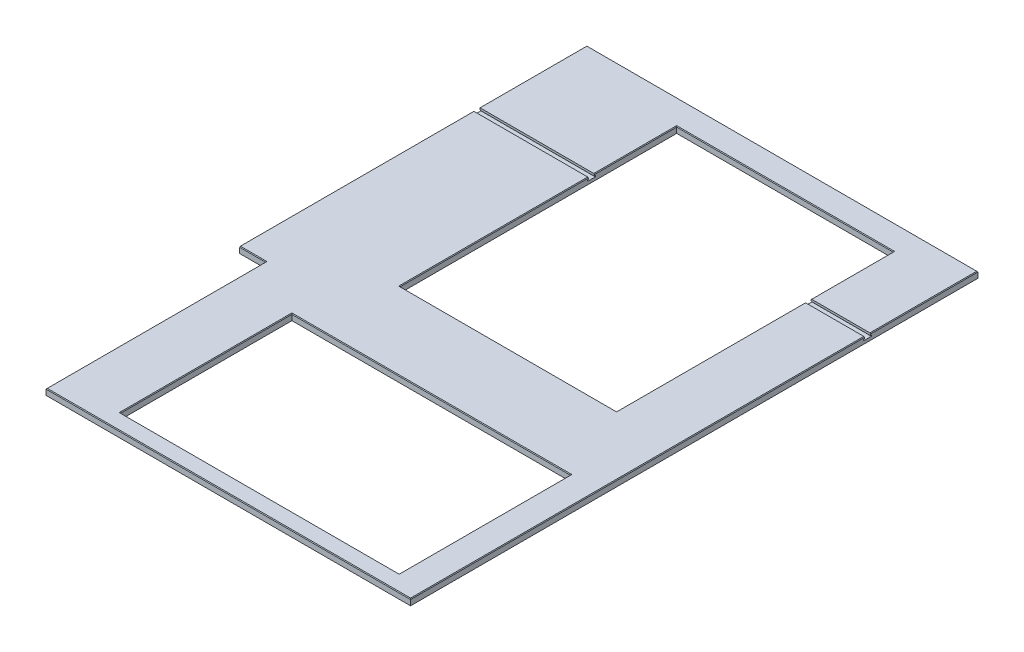
from build123d import *

# Parameters (mm, degrees)
SKETCH1_W           = 1219.2
SKETCH1_H           = 1771.65
BOSS_EXTRUDE1_DEPTH = 19.05
SKETCH2_W           = 869.95
SKETCH2_H           = 534.9875
CUT_EXTRUDE1_DEPTH  = 20.05
SKETCH3_W           = 80.9625
SKETCH3_H           = 685.8
CUT_EXTRUDE2_DEPTH  = 20.05
SKETCH4_W           = 676.20134
SKETCH4_H           = 863.85146
CUT_EXTRUDE3_DEPTH  = 20.05
CUT_EXTRUDE4_DEPTH  = 1220.2
CHAMFER1_SIZE       = 2.032


with BuildPart() as part:
    # Sketch1 → Boss-Extrude1 (new body)
    with BuildSketch(Plane(origin=(0, 0, 0), x_dir=(1, 0, 0), z_dir=(0, 1, 0))):
        with Locations((609.6, 885.825)):
            Rectangle(SKETCH1_W, SKETCH1_H)
    extrude(amount=-BOSS_EXTRUDE1_DEPTH)

    # Sketch2 → Cut-Extrude1 (cut, through all)
    with BuildSketch(Plane(origin=(0, 0, 0), x_dir=(1, 0, 0), z_dir=(0, 1, 0))):
        with Locations((697.865, 318.29375)):
            Rectangle(SKETCH2_W, SKETCH2_H)
    extrude(amount=-CUT_EXTRUDE1_DEPTH, mode=Mode.SUBTRACT)

    # Sketch3 → Cut-Extrude2 (cut, through all)
    with BuildSketch(Plane(origin=(0, 0, 0), x_dir=(1, 0, 0), z_dir=(0, 1, 0))):
        with Locations((40.48125, 342.9)):
            Rectangle(SKETCH3_W, SKETCH3_H)
    extrude(amount=-CUT_EXTRUDE2_DEPTH, mode=Mode.SUBTRACT)

    # Sketch4 → Cut-Extrude3 (cut, through all)
    with BuildSketch(Plane(origin=(0, 0, 0), x_dir=(1, 0, 0), z_dir=(0, 1, 0))):
        with Locations((695.28817, 1260.98427)):
            Rectangle(SKETCH4_W, SKETCH4_H)
    extrude(amount=-CUT_EXTRUDE3_DEPTH, mode=Mode.SUBTRACT)

    # Sketch5 → Cut-Extrude4 (cut, through all)
    with BuildSketch(Plane.ZY):
        Polygon((-1436.1414, 0), (-1417.0914, 0), (-1417.0914, -5.969), (-1414.4244, -5.969), (-1414.4244, -9.525), (-1438.8084, -9.525), (-1438.8084, -5.969), (-1436.1414, -5.969), align=None)
    extrude(amount=-CUT_EXTRUDE4_DEPTH, mode=Mode.SUBTRACT)

    # Chamfer1
    chamfer1_edges = [part.edges().sort_by_distance(p)[0] for p in [
        (1132.84, 0, -318.29375),
        (697.865, 0, -585.7875),
        (262.89, 0, -318.29375),
        (697.865, 0, -50.8),
        (650.08125, 0, 0),
        (80.9625, 0, -342.9),
        (40.48125, 0, -685.8),
        (1033.38884, 0, -1123.07497),
        (695.28817, 0, -1692.91),
        (357.1875, 0, -1564.5257),
        (695.28817, 0, -829.05854),
        (609.6, 0, -1771.65),
        (1219.2, 0, -708.5457),
        (357.1875, 0, -1123.07497),
        (1033.38884, 0, -1564.5257),
        (1219.2, 0, -1603.8957),
    ]]
    chamfer(chamfer1_edges, length=CHAMFER1_SIZE)


solid = part.part
